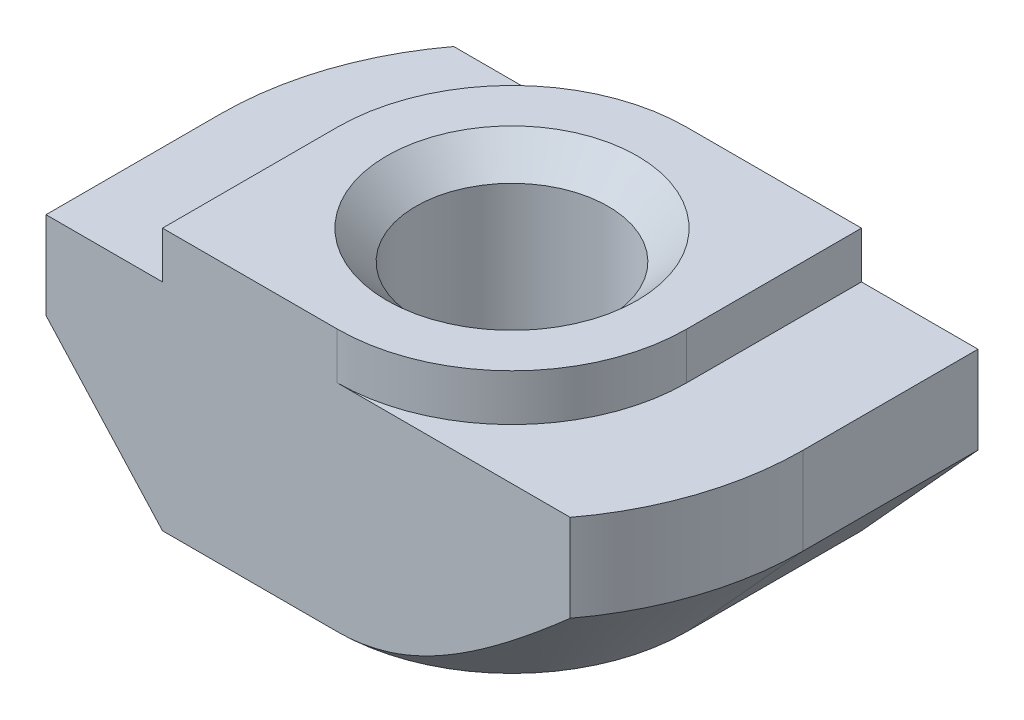
from build123d import *

# Parameters (mm, degrees)
EXTRUDE_1_DEPTH     = 3
CUT_EXTRUDE_1_DEPTH = 0.8
CUT_EXTRUDE_2_DEPTH = 4.7


with BuildPart() as part:
    # Эскиз1 → Бобышка-Вытянуть1 (new body, symmetric)
    with BuildSketch(Plane.XY):
        Polygon((3, 0), (-3, 0), (-3, -0.8), (-5, -0.8), (-5, -4.5), (5, -4.5), (5, -0.8), (3, -0.8), align=None)
    extrude(amount=EXTRUDE_1_DEPTH, both=True)

    # Эскиз3 → Отверстие обработанное метчиком M41 (revolve, cut)
    with BuildSketch(Plane(origin=(0, 0, 0), x_dir=(0, 0, 1), z_dir=(1, 0, 0))):
        Polygon((0, 0), (0, 4.5), (2.15, 4.5), (1.65, 4), (1.65, 0.5), (2.15, 0), align=None)
    revolve(axis=Axis((0, 6.35, 0), (0, -1, 0)), mode=Mode.SUBTRACT)

    # Эскиз4 → Вырез-Вытянуть1 (cut)
    with BuildSketch(Plane(origin=(0, 0, 0), x_dir=(1, 0, 0), z_dir=(0, 1, 0))):
        with BuildLine():
            Line((-3, 3), (-3, 0))
            ThreePointArc((-3, 0), (-2.121320344, 2.121320344), (0, 3))
            Line((0, 3), (-3, 3))
        make_face()
        with BuildLine():
            Line((0, -3), (3, -3))
            Line((3, -3), (3, 0))
            ThreePointArc((3, 0), (2.121320344, -2.121320344), (0, -3))
        make_face()
    extrude(amount=-CUT_EXTRUDE_1_DEPTH, mode=Mode.SUBTRACT)

    # Эскиз5 → Вырез-Вытянуть2 (cut, through all)
    with BuildSketch(Plane(origin=(0, -0.8, 0), x_dir=(1, 0, 0), z_dir=(0, 1, 0))):
        with BuildLine():
            Line((-5, 0), (-5, 3))
            Line((-5, 3), (-4, 3))
            ThreePointArc((-4, 3), (-4.74341649, 1.58113883), (-5, 0))
        make_face()
        with BuildLine():
            Line((5, 0), (5, -3))
            Line((5, -3), (4, -3))
            ThreePointArc((4, -3), (4.74341649, -1.58113883), (5, 0))
        make_face()
    extrude(amount=-CUT_EXTRUDE_2_DEPTH, mode=Mode.SUBTRACT)

    # Вырез-По траектории1: sweep along a path in Эскиз7
    with BuildLine(Plane.XZ.offset(4.5)) as sweep_1_path:
        Line((0, 5), (-5, 5))
        Line((-5, 5), (-5, 0))
        ThreePointArc((-5, 0), (-3.535533906, -3.535533906), (0, -5))
        Line((0, -5), (5, -5))
        Line((5, -5), (5, 0))
        ThreePointArc((5, 0), (3.535533906, 3.535533906), (0, 5))
    # Эскиз6 → Вырез-По траектории1 (sweep, cut)
    with BuildSketch(Plane.XY.offset(3)):
        Polygon((-5, -2.3), (-5, -4.5), (-3, -4.5), align=None)
    sweep(path=sweep_1_path.line, transition=Transition.RIGHT, mode=Mode.SUBTRACT)


solid = part.part
